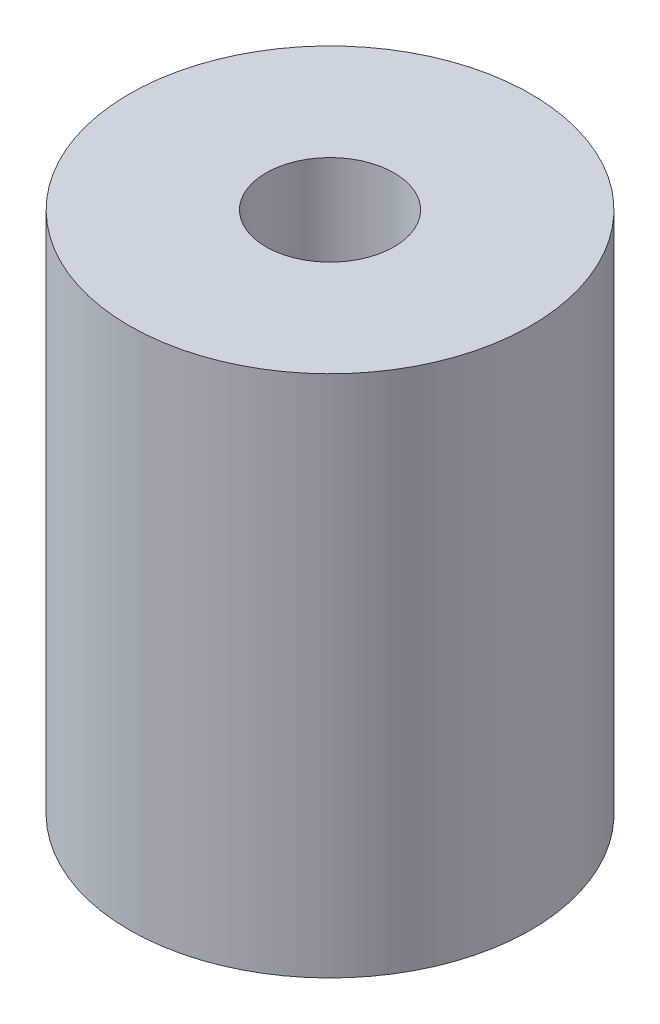
from build123d import *

# Parameters (mm, degrees)
SKETCH2_R           = 9.4
BOSS_EXTRUDE1_DEPTH = 24.5
SKETCH3_R           = 3
CUT_EXTRUDE1_DEPTH  = 7.9
SKETCH4_R           = 3.175
CUT_EXTRUDE2_DEPTH  = 16.6


with BuildPart() as part:
    # Sketch2 → Boss-Extrude1 (new body)
    with BuildSketch(Plane(origin=(0, 0, 0), x_dir=(1, 0, 0), z_dir=(0, 1, 0))):
        Circle(SKETCH2_R)
    extrude(amount=BOSS_EXTRUDE1_DEPTH)

    # Sketch3 → Cut-Extrude1 (cut)
    with BuildSketch(Plane(origin=(0, 24.5, 0), x_dir=(1, 0, 0), z_dir=(0, 1, 0))):
        Circle(SKETCH3_R)
    extrude(amount=-CUT_EXTRUDE1_DEPTH, mode=Mode.SUBTRACT)

    # Sketch4 → Cut-Extrude2 (cut)
    with BuildSketch(Plane.XZ):
        Circle(SKETCH4_R)
    extrude(amount=-CUT_EXTRUDE2_DEPTH, mode=Mode.SUBTRACT)


solid = part.part
